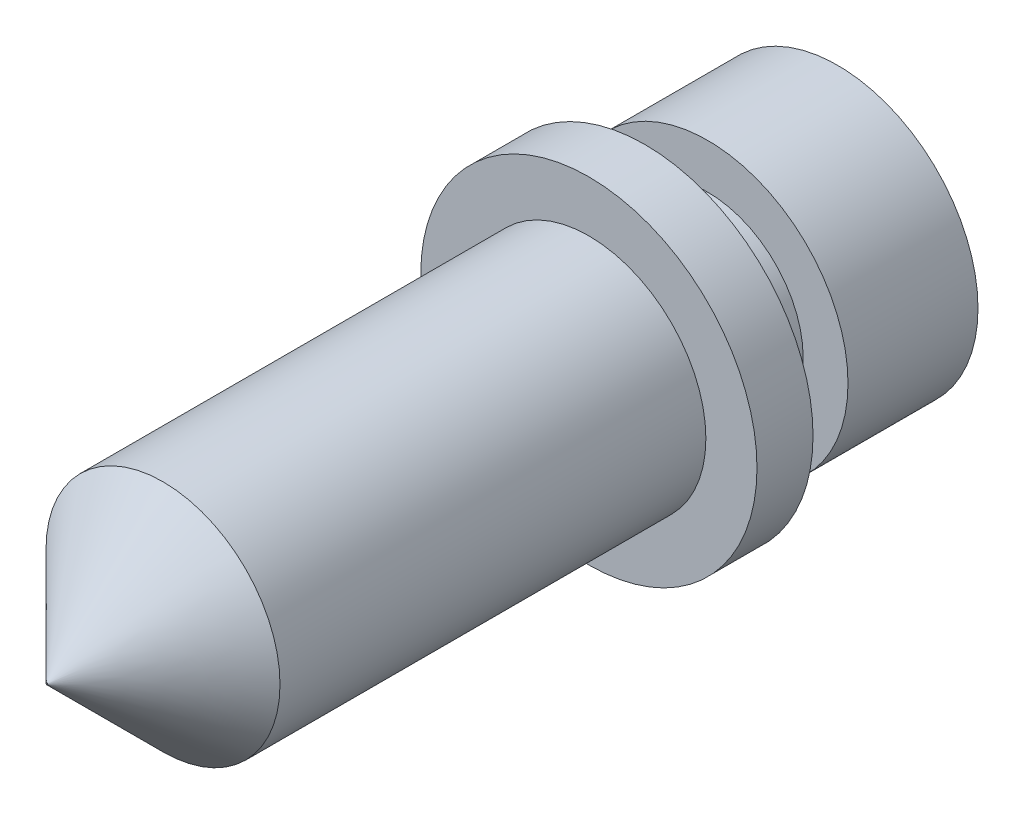
from build123d import *

# Parameters (mm, degrees)
SKETCH1_R           = 4.7625
BOSS_EXTRUDE1_DEPTH = 0.79375
SKETCH2_R           = 3.9751
BOSS_EXTRUDE2_DEPTH = 5.461
SKETCH3_R           = 3.3147
BOSS_EXTRUDE3_DEPTH = 12.065
SKETCH6_R           = 1.5875
CUT_EXTRUDE1_DEPTH  = 19.05
SKETCH10_W          = 1.27
SKETCH10_H          = 1.778
SKETCH11_R          = 0.0508
CUT_EXTRUDE3_DEPTH  = 0.0254
SKETCH9_R           = 0.02
CUT_EXTRUDE2_DEPTH  = 23.4028
CHAMFER1_SIZE       = 1.27


with BuildPart() as part:
    # Sketch1 → Boss-Extrude1 (new body, symmetric)
    with BuildSketch(Plane.XY):
        Circle(SKETCH1_R)
    extrude(amount=BOSS_EXTRUDE1_DEPTH, both=True)

    # Sketch2 → Boss-Extrude2 (add)
    with BuildSketch(Plane(origin=(0, 0, -0.79375), x_dir=(-1, 0, 0), z_dir=(0, 0, -1))):
        with Locations(Location((0, 0, 0), (0, 0, 180))):  # turned: the seam where the file's is
            Circle(SKETCH2_R)
    extrude(amount=BOSS_EXTRUDE2_DEPTH)

    # Sketch3 → Boss-Extrude3 (add)
    with BuildSketch(Plane.XY.offset(0.79375)):
        Circle(SKETCH3_R)
    extrude(amount=BOSS_EXTRUDE3_DEPTH)

    # Sketch5 → Revolve1 (revolve)
    with BuildSketch(Plane(origin=(0, 0, 0), x_dir=(0, 0, -1), z_dir=(1, 0, 0)), mode=Mode.PRIVATE) as revolve1_sk:
        Polygon((-12.85875, 3.3147), (-16.17345, 0), (-12.85875, 0), align=None)
    revolve(revolve1_sk.sketch.rotate(Axis((0, 0, 0), (0, 0, 1)), 270), axis=Axis((0, 0, 0), (0, 0, 1)))  # turned: the seam where the file's is

    # Sketch6 → Cut-Extrude1 (cut)
    with BuildSketch(Plane(origin=(0, 0, -6.25475), x_dir=(-1, 0, 0), z_dir=(0, 0, -1))):
        Circle(SKETCH6_R)
    extrude(amount=-CUT_EXTRUDE1_DEPTH, mode=Mode.SUBTRACT)

    # Sketch10 → Cut-Revolve1 (revolve, cut)
    with BuildSketch(Plane(origin=(0, 0, 0), x_dir=(1, 0, 0), z_dir=(0, 1, 0)), mode=Mode.PRIVATE) as cut_revolve1_sk:
        with Locations((-3.3401, 1.68275)):
            Rectangle(SKETCH10_W, SKETCH10_H)
    revolve(cut_revolve1_sk.sketch.rotate(Axis((0, 0, 0), (0, 0, -1)), 180), axis=Axis((0, 0, 0), (0, 0, -1)), mode=Mode.SUBTRACT)  # turned: the seam where the file's is

    # Sketch11 → Cut-Extrude3 (cut)
    with BuildSketch(Plane.XY.offset(16.17345)):
        Circle(SKETCH11_R)
    extrude(amount=-CUT_EXTRUDE3_DEPTH, mode=Mode.SUBTRACT)

    # Sketch9 → Cut-Extrude2 (cut, through all)
    with BuildSketch(Plane(origin=(0, 0, -6.25475), x_dir=(-1, 0, 0), z_dir=(0, 0, -1))):
        Circle(SKETCH9_R)
    extrude(amount=-CUT_EXTRUDE2_DEPTH, mode=Mode.SUBTRACT)

    # Chamfer1
    chamfer1_edges = [part.edges().sort_by_distance(p)[0] for p in [
        (1.5875, 0, -6.25475),
    ]]
    chamfer(chamfer1_edges, length=CHAMFER1_SIZE)


solid = part.part
